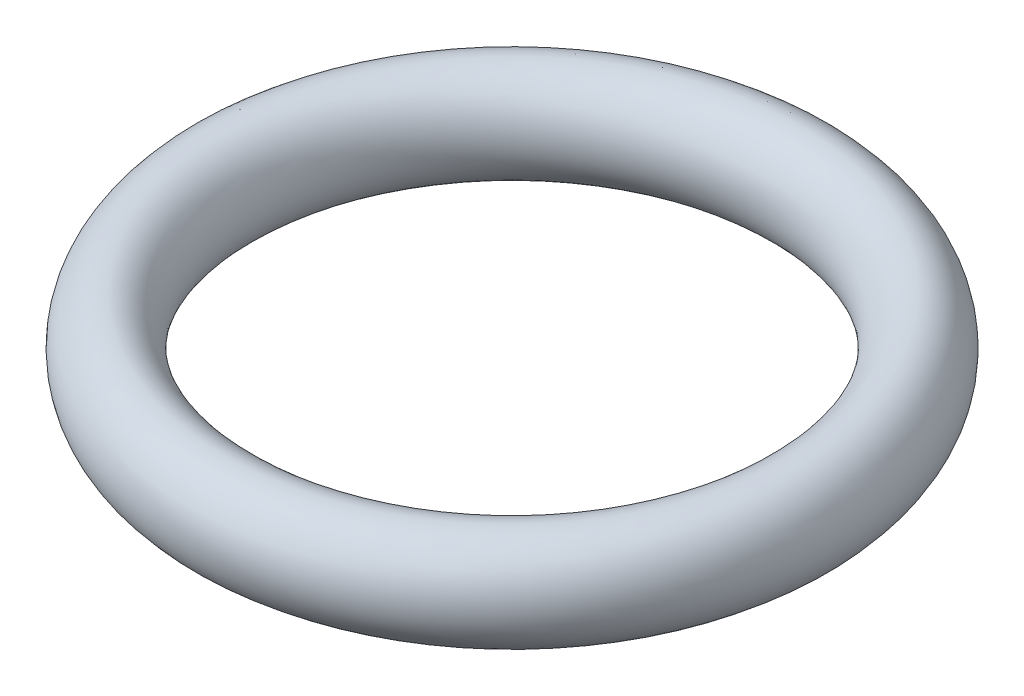
from build123d import *

# Parameters (mm, degrees)
BODY_SKETCH_RX = 1
BODY_SKETCH_RY = 0.85485


with BuildPart() as part:
    # body_sketch → body (revolve)
    with BuildSketch(Plane.XY):
        with Locations(Location((-5.79515, 0), (0, 0, 90))):
            Ellipse(BODY_SKETCH_RX, BODY_SKETCH_RY)
    revolve(axis=Axis((0, 1, 0), (0, -1, 0)))


solid = part.part
